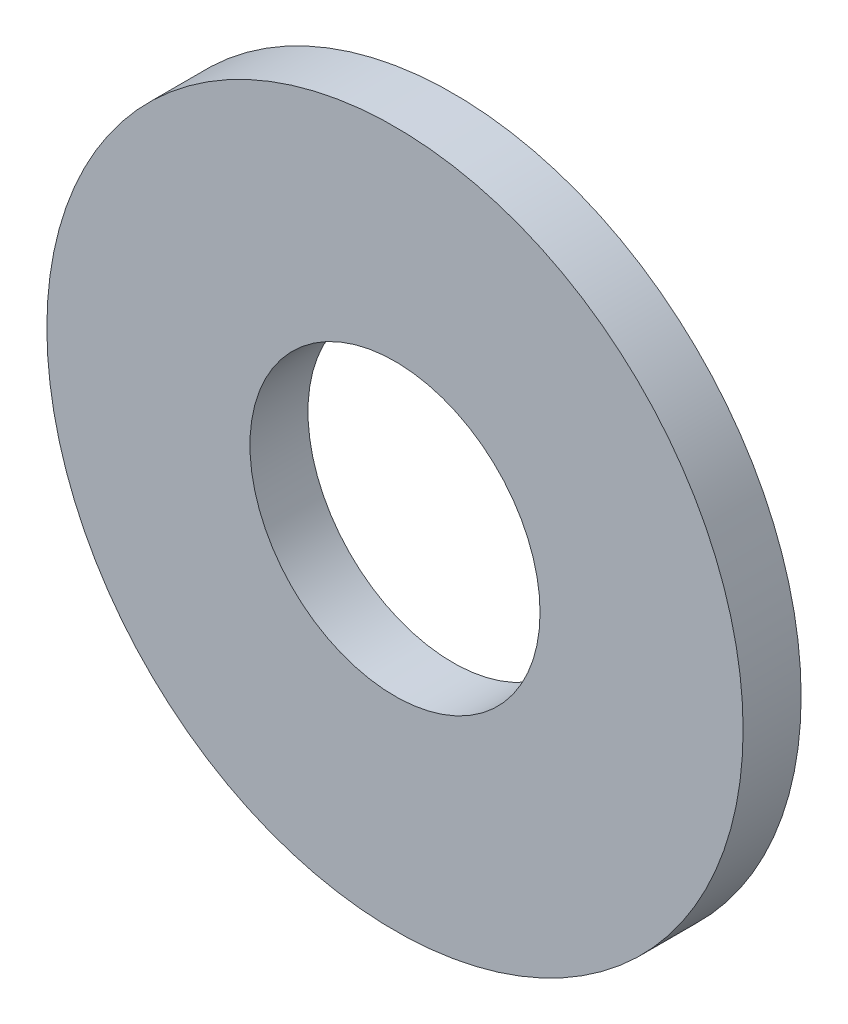
from build123d import *

# Parameters (mm, degrees)
ESQUISSE1_R      = 6
ESQUISSE1_R_2    = 2.5
EXTRUSION1_DEPTH = 1


with BuildPart() as part:
    # Esquisse1 → Extrusion1 (new body)
    with BuildSketch(Plane.XY):
        Circle(ESQUISSE1_R)
        Circle(ESQUISSE1_R_2, mode=Mode.SUBTRACT)
    extrude(amount=EXTRUSION1_DEPTH)


solid = part.part
